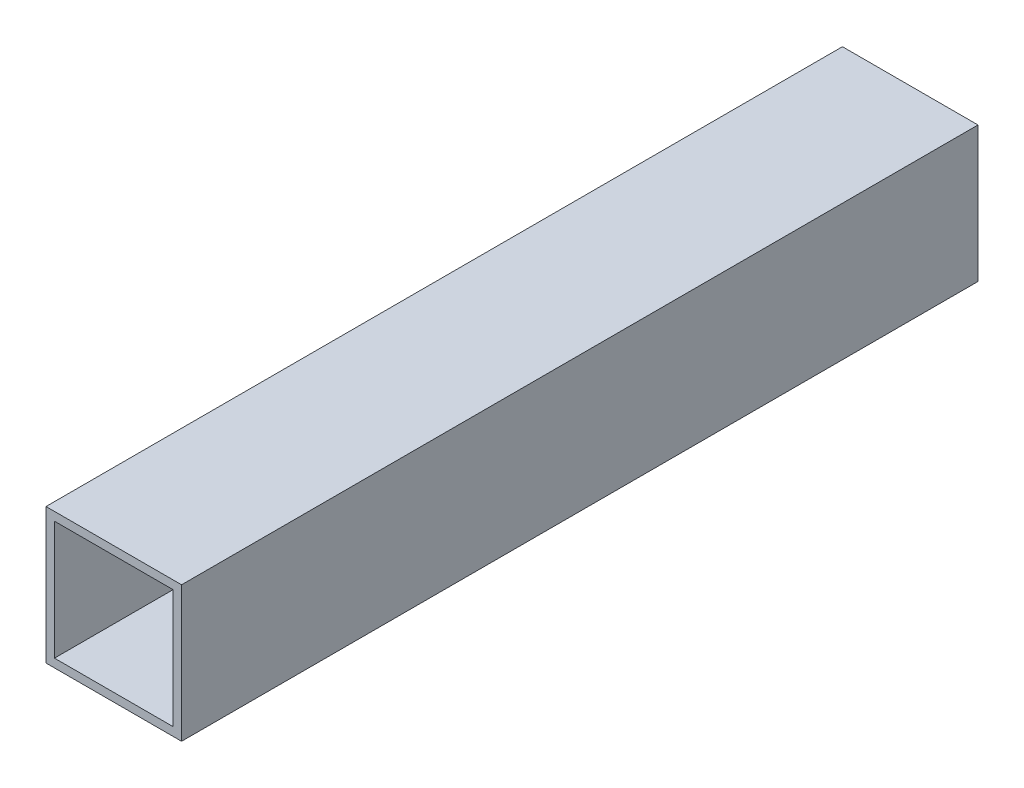
from build123d import *

# Parameters (mm, degrees)
SKETCH3_W                = 25.4
SKETCH3_H                = 25.4
SKETCH3_W_2              = 22.225
SKETCH3_H_2              = 22.225
BOSS_EXTRUDE1_DEPTH      = 76.2
BOSS_EXTRUDE1_DEPTH_BACK = 76.2
SKETCH4_W                = 25.4
SKETCH4_H                = 25.4
SKETCH4_W_2              = 22.225
SKETCH4_H_2              = 22.225
CUT_EXTRUDE1_DEPTH       = 3.175


with BuildPart() as part:
    # Sketch3 → Boss-Extrude1 (new body, two sides)
    with BuildSketch(Plane.XY) as boss_extrude1_sk:
        Rectangle(SKETCH3_W, SKETCH3_H)
        Rectangle(SKETCH3_W_2, SKETCH3_H_2, mode=Mode.SUBTRACT)
    extrude(amount=BOSS_EXTRUDE1_DEPTH)
    extrude(boss_extrude1_sk.sketch, amount=-BOSS_EXTRUDE1_DEPTH_BACK)

    # Sketch4 → Cut-Extrude1 (cut)
    with BuildSketch(Plane(origin=(0, 0, -76.2), x_dir=(-1, 0, 0), z_dir=(0, 0, -1))):
        Rectangle(SKETCH4_W, SKETCH4_H)
        Rectangle(SKETCH4_W_2, SKETCH4_H_2, mode=Mode.SUBTRACT)
    extrude(amount=-CUT_EXTRUDE1_DEPTH, mode=Mode.SUBTRACT)


solid = part.part
